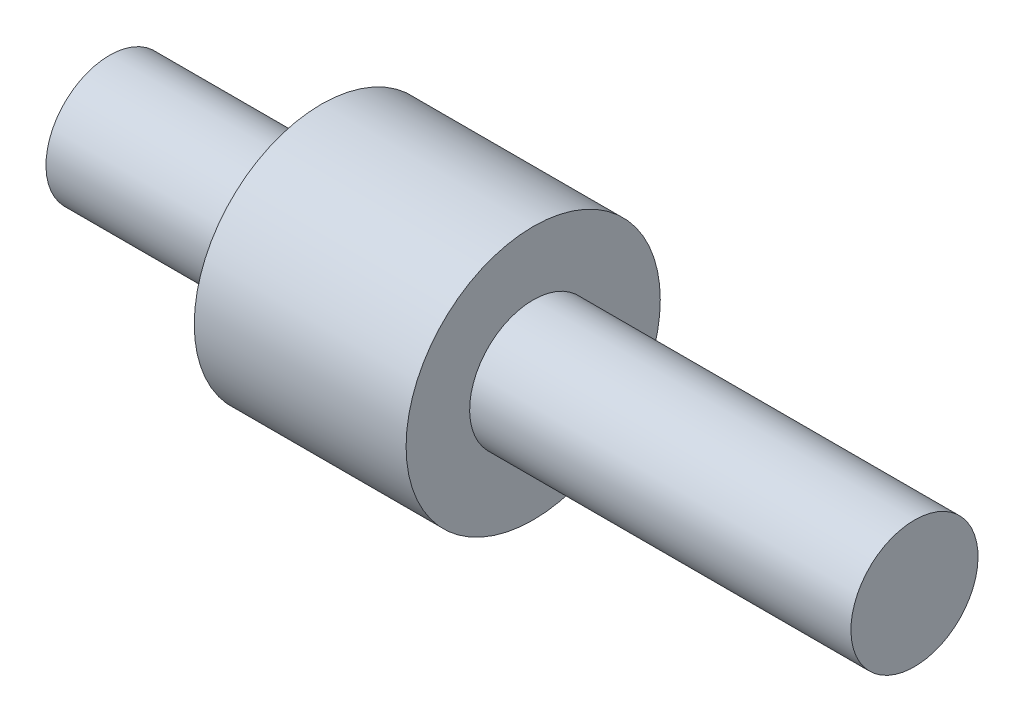
from build123d import *


with BuildPart() as part:
    # Esquisse1 → Révolution1 (revolve)
    with BuildSketch(Plane.XY):
        Polygon((0, 0), (0, 1.5), (5, 1.5), (5, 3), (10, 3), (10, 1.5), (19, 1.5), (19, 0), align=None)
    revolve(axis=Axis((19, 0, 0), (-1, 0, 0)))


solid = part.part
